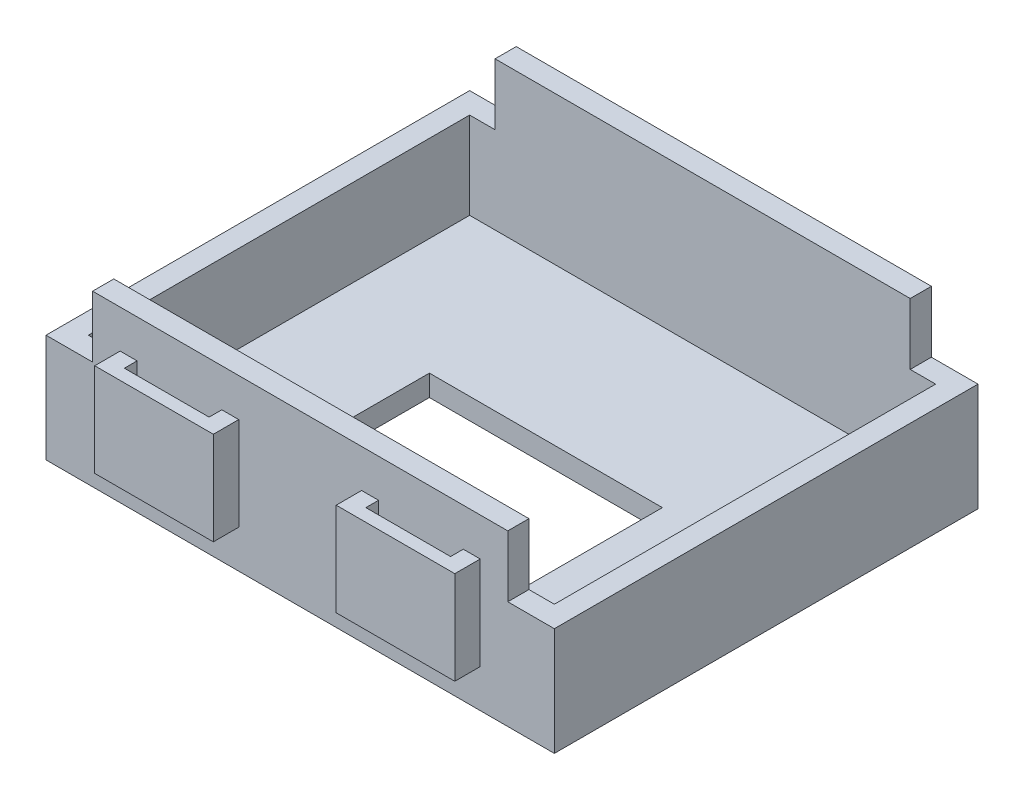
from build123d import *

# Parameters (mm, degrees)
CROQUIS1_W              = 60
CROQUIS1_H              = 50
SALIENTE_EXTRUIR1_DEPTH = 12.75
CORTAR_EXTRUIR2_START   = 12.75
CROQUIS2_W              = 55
CROQUIS2_H              = 45
CORTAR_EXTRUIR2_DEPTH   = 10.25
SALIENTE_EXTRUIR2_START = 25
CROQUIS4_W              = 49
CROQUIS4_H              = 7.25
SALIENTE_EXTRUIR2_DEPTH = 2.5
SALIENTE_EXTRUIR3_START = -25
CROQUIS4_2_W            = 49
CROQUIS4_2_H            = 7.25
SALIENTE_EXTRUIR3_DEPTH = 2.5
CROQUIS5_W              = 27.5
CROQUIS5_H              = 20
CORTAR_EXTRUIR3_DEPTH   = 10
SALIENTE_EXTRUIR5_START = 25
CROQUIS6_W              = 14
CROQUIS6_H              = 11
SALIENTE_EXTRUIR5_DEPTH = 3
SALIENTE_EXTRUIR6_START = -25
CROQUIS6_2_W            = 14
CROQUIS6_2_H            = 11
SALIENTE_EXTRUIR6_DEPTH = 3
CROQUIS8_W              = 10
CROQUIS8_H              = 1.5
CORTAR_EXTRUIR5_DEPTH   = 43.5
CROQUIS9_W              = 4
CROQUIS9_H              = 8.75
CROQUIS9_W_2            = 6.15
CROQUIS9_H_2            = 6
CORTAR_EXTRUIR6_DEPTH   = 43.5


with BuildPart() as part:
    # Croquis1 → Saliente-Extruir1 (new body)
    with BuildSketch(Plane(origin=(0, 0, 0), x_dir=(1, 0, 0), z_dir=(0, 1, 0))):
        Rectangle(CROQUIS1_W, CROQUIS1_H)
    extrude(amount=SALIENTE_EXTRUIR1_DEPTH)

    # Croquis2 → Cortar-Extruir2 (cut)
    with BuildSketch(Plane(origin=(0, 0, 0), x_dir=(1, 0, 0), z_dir=(0, 1, 0)).offset(CORTAR_EXTRUIR2_START)):
        Rectangle(CROQUIS2_W, CROQUIS2_H)
    extrude(amount=-CORTAR_EXTRUIR2_DEPTH, mode=Mode.SUBTRACT)

    # Croquis4 → Saliente-Extruir2 (add)
    with BuildSketch(Plane.XY.offset(SALIENTE_EXTRUIR2_START)):
        with Locations((0, 16.375)):
            Rectangle(CROQUIS4_W, CROQUIS4_H)
    extrude(amount=-SALIENTE_EXTRUIR2_DEPTH)

    # Croquis4_2 → Saliente-Extruir3 (add)
    with BuildSketch(Plane.XY.offset(SALIENTE_EXTRUIR3_START)):
        with Locations((0, 16.375)):
            Rectangle(CROQUIS4_2_W, CROQUIS4_2_H)
    extrude(amount=SALIENTE_EXTRUIR3_DEPTH)

    # Croquis5 → Cortar-Extruir3 (cut)
    with BuildSketch(Plane(origin=(0, 0, 0), x_dir=(1, 0, 0), z_dir=(0, 1, 0))):
        with Locations((0, -6)):
            Rectangle(CROQUIS5_W, CROQUIS5_H)
    extrude(amount=CORTAR_EXTRUIR3_DEPTH, mode=Mode.SUBTRACT)

    # Croquis6 → Saliente-Extruir5 (add)
    with BuildSketch(Plane.XY.offset(SALIENTE_EXTRUIR5_START)):
        with Locations((-14.25, 10)):
            Rectangle(CROQUIS6_W, CROQUIS6_H)
        with Locations((14.25, 10)):
            Rectangle(CROQUIS6_W, CROQUIS6_H)
    extrude(amount=SALIENTE_EXTRUIR5_DEPTH)

    # Croquis6_2 → Saliente-Extruir6 (add)
    with BuildSketch(Plane.XY.offset(SALIENTE_EXTRUIR6_START)):
        with Locations((-14.25, 10)):
            Rectangle(CROQUIS6_2_W, CROQUIS6_2_H)
        with Locations((14.25, 10)):
            Rectangle(CROQUIS6_2_W, CROQUIS6_2_H)
    extrude(amount=-SALIENTE_EXTRUIR6_DEPTH)

    # Croquis8 → Cortar-Extruir5 (cut)
    with BuildSketch(Plane(origin=(0, 0, 0), x_dir=(1, 0, 0), z_dir=(0, 1, 0))):
        with Locations((-14.25, 25.75)):
            Rectangle(CROQUIS8_W, CROQUIS8_H)
        with Locations((14.25, 25.75)):
            Rectangle(CROQUIS8_W, CROQUIS8_H)
        with Locations((14.25, -25.75)):
            Rectangle(CROQUIS8_W, CROQUIS8_H)
        with Locations((-14.25, -25.75)):
            Rectangle(CROQUIS8_W, CROQUIS8_H)
    extrude(amount=CORTAR_EXTRUIR5_DEPTH, mode=Mode.SUBTRACT)

    # Croquis9 → Cortar-Extruir6 (cut)
    with BuildSketch(Plane(origin=(0, 0, 0), x_dir=(1, 0, 0), z_dir=(0, 1, 0))):
        with Locations((-22.5, -15.125)):
            Rectangle(CROQUIS9_W, CROQUIS9_H)
        with Locations((21.425, -16.5)):
            Rectangle(CROQUIS9_W_2, CROQUIS9_H_2)
    extrude(amount=CORTAR_EXTRUIR6_DEPTH, mode=Mode.SUBTRACT)


solid = part.part
